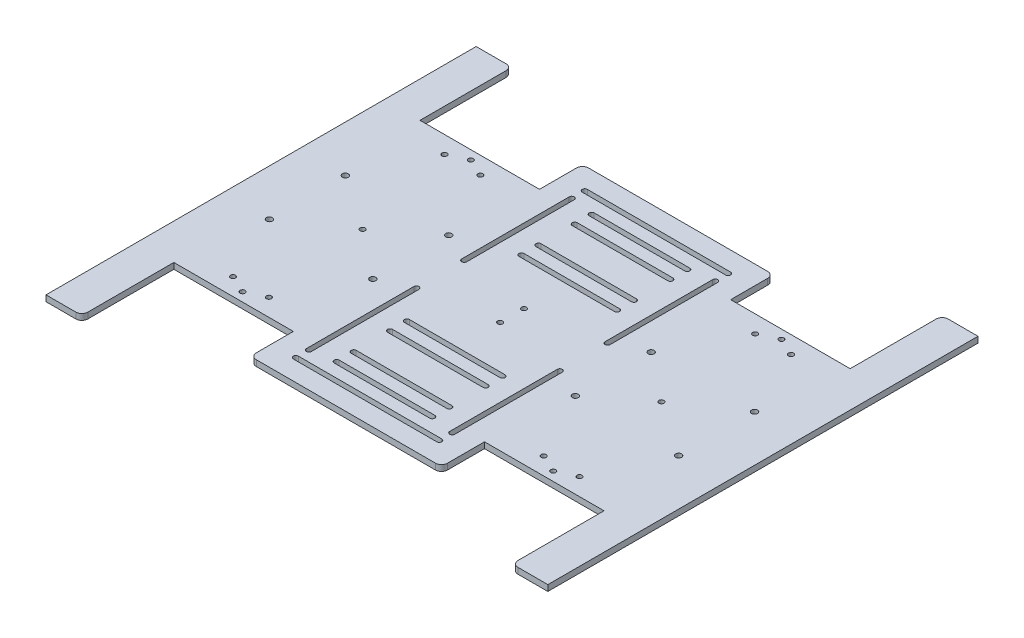
from build123d import *

# Parameters (mm, degrees)
EXTRUDE_1_DEPTH     = 5
SKETCH_2_R          = 2.1
CUT_EXTRUDE_1_DEPTH = 6
FILLET_1_R          = 5
SKETCH_3_R          = 2.5
CUT_EXTRUDE_2_DEPTH = 6
SKETCH_4_R          = 2.1
CUT_EXTRUDE_3_DEPTH = 6
SKETCH_5_W          = 160
SKETCH_5_H          = 66.889435481
CUT_EXTRUDE_4_DEPTH = 6
FILLET_2_R          = 5
CUT_EXTRUDE_5_DEPTH = 6


with BuildPart() as part:
    # 草图1 → 凸台-拉伸1 (new body)
    with BuildSketch(Plane(origin=(0, 0, 0), x_dir=(1, 0, 0), z_dir=(0, 1, 0))):
        Polygon((-180, 180), (-180, 103), (-80, 103), (-80, 180), (80, 180), (80, 103), (180, 103), (180, 180), (210, 180), (210, -180), (180, -180), (180, -103), (80, -103), (80, -180), (-80, -180), (-80, -103), (-180, -103), (-180, -180), (-210, -180), (-210, 180), align=None)
    extrude(amount=EXTRUDE_1_DEPTH)

    # 草图2 → 切除-拉伸1 (cut, through all)
    with BuildSketch(Plane(origin=(0, 5, 0), x_dir=(1, 0, 0), z_dir=(0, 1, 0))):
        with Locations((115, -88.5)):
            Circle(SKETCH_2_R)
        with Locations((145, -88.5)):
            Circle(SKETCH_2_R)
        with Locations((130, -95.5)):
            Circle(SKETCH_2_R)
        with Locations((130, 95.5)):
            Circle(SKETCH_2_R)
        with Locations((145, 88.5)):
            Circle(SKETCH_2_R)
        with Locations((115, 88.5)):
            Circle(SKETCH_2_R)
        with Locations((-115, 88.5)):
            Circle(SKETCH_2_R)
        with Locations((-145, 88.5)):
            Circle(SKETCH_2_R)
        with Locations((-130, 95.5)):
            Circle(SKETCH_2_R)
        with Locations((-130, -95.5)):
            Circle(SKETCH_2_R)
        with Locations((-145, -88.5)):
            Circle(SKETCH_2_R)
        with Locations((-115, -88.5)):
            Circle(SKETCH_2_R)
    extrude(amount=-CUT_EXTRUDE_1_DEPTH, mode=Mode.SUBTRACT)

    # 圆角1
    fillet_1_edges = [part.edges().sort_by_distance(p)[0] for p in [
        (180, 2.5, 180),
        (80, 2.5, 180),
        (-80, 2.5, 180),
        (-180, 2.5, 180),
        (-180, 2.5, -180),
        (-80, 2.5, -180),
        (80, 2.5, -180),
        (180, 2.5, -180),
    ]]
    fillet(fillet_1_edges, radius=FILLET_1_R)

    # 草图3 → 切除-拉伸2 (cut, through all)
    with BuildSketch(Plane.XZ):
        with Locations((84.75, 31.75)):
            Circle(SKETCH_3_R)
        with Locations((84.75, -31.75)):
            Circle(SKETCH_3_R)
        with Locations((171.25, 31.75)):
            Circle(SKETCH_3_R)
        with Locations((171.25, -31.75)):
            Circle(SKETCH_3_R)
        with Locations((-171.25, -31.75)):
            Circle(SKETCH_3_R)
        with Locations((-171.25, 31.75)):
            Circle(SKETCH_3_R)
        with Locations((-84.75, -31.75)):
            Circle(SKETCH_3_R)
        with Locations((-84.75, 31.75)):
            Circle(SKETCH_3_R)
    extrude(amount=-CUT_EXTRUDE_2_DEPTH, mode=Mode.SUBTRACT)

    # 草图4 → 切除-拉伸3 (cut, through all)
    with BuildSketch(Plane.XZ):
        with Locations((-125, 0)):
            Circle(SKETCH_4_R)
        with Locations((125, 0)):
            Circle(SKETCH_4_R)
        with Locations((0, 10)):
            Circle(SKETCH_4_R)
        with Locations((0, -10)):
            Circle(SKETCH_4_R)
    extrude(amount=-CUT_EXTRUDE_3_DEPTH, mode=Mode.SUBTRACT)

    # 草图5 → 切除-拉伸4 (cut, through all)
    with BuildSketch(Plane(origin=(0, 5, 0), x_dir=(1, 0, 0), z_dir=(0, 1, 0))):
        with Locations((0, -172.444717741)):
            Rectangle(SKETCH_5_W, SKETCH_5_H)
        Polygon((80, 139), (-80, 139), (-80, 214.558464343), (80, 221.06023599), align=None)
    extrude(amount=-CUT_EXTRUDE_4_DEPTH, mode=Mode.SUBTRACT)

    # 圆角2
    fillet_2_edges = [part.edges().sort_by_distance(p)[0] for p in [
        (-80, 2.5, 139),
        (80, 2.5, 139),
        (80, 2.5, -139),
        (-80, 2.5, -139),
    ]]
    fillet(fillet_2_edges, radius=FILLET_2_R)

    # 草图6 → 切除-拉伸5 (cut, through all)
    with BuildSketch(Plane(origin=(0, 5, 0), x_dir=(1, 0, 0), z_dir=(0, 1, 0))):
        with BuildLine():
            Line((-60, 123), (60, 123))
            ThreePointArc((60, 123), (62.1, 120.9), (60, 118.8))
            Line((60, 118.8), (-60, 118.8))
            ThreePointArc((-60, 118.8), (-62.1, 120.9), (-60, 123))
        make_face()
        with BuildLine():
            Line((-40, 108.8), (40, 108.8))
            ThreePointArc((40, 108.8), (42.1, 106.7), (40, 104.6))
            Line((40, 104.6), (-40, 104.6))
            ThreePointArc((-40, 104.6), (-42.1, 106.7), (-40, 108.8))
        make_face()
        with BuildLine():
            Line((-62.1, 110), (-62.1, 20))
            ThreePointArc((-62.1, 20), (-60, 17.9), (-57.9, 20))
            Line((-57.9, 20), (-57.9, 110))
            ThreePointArc((-57.9, 110), (-60, 112.1), (-62.1, 110))
        make_face()
        with BuildLine():
            Line((-40, 94.6), (40, 94.6))
            ThreePointArc((40, 94.6), (42.1, 92.5), (40, 90.4))
            Line((40, 90.4), (-40, 90.4))
            ThreePointArc((-40, 90.4), (-42.1, 92.5), (-40, 94.6))
        make_face()
        with BuildLine():
            Line((62.1, 110), (62.1, 20))
            ThreePointArc((62.1, 20), (60, 17.9), (57.9, 20))
            Line((57.9, 20), (57.9, 110))
            ThreePointArc((57.9, 110), (60, 112.1), (62.1, 110))
        make_face()
        with BuildLine():
            Line((-40, 64.2), (40, 64.2))
            ThreePointArc((40, 64.2), (42.1, 62.1), (40, 60))
            Line((40, 60), (-40, 60))
            ThreePointArc((-40, 60), (-42.1, 62.1), (-40, 64.2))
        make_face()
        with BuildLine():
            Line((-40, 50), (40, 50))
            ThreePointArc((40, 50), (42.1, 47.9), (40, 45.8))
            Line((40, 45.8), (-40, 45.8))
            ThreePointArc((-40, 45.8), (-42.1, 47.9), (-40, 50))
        make_face()
        with BuildLine():
            Line((40, -60), (-40, -60))
            ThreePointArc((-40, -60), (-42.1, -62.1), (-40, -64.2))
            Line((-40, -64.2), (40, -64.2))
            ThreePointArc((40, -64.2), (42.1, -62.1), (40, -60))
        make_face()
        with BuildLine():
            Line((40, -45.8), (-40, -45.8))
            ThreePointArc((-40, -45.8), (-42.1, -47.9), (-40, -50))
            Line((-40, -50), (40, -50))
            ThreePointArc((40, -50), (42.1, -47.9), (40, -45.8))
        make_face()
        with BuildLine():
            Line((-57.9, -110), (-57.9, -20))
            ThreePointArc((-57.9, -20), (-60, -17.9), (-62.1, -20))
            Line((-62.1, -20), (-62.1, -110))
            ThreePointArc((-62.1, -110), (-60, -112.1), (-57.9, -110))
        make_face()
        with BuildLine():
            Line((57.9, -20), (57.9, -110))
            ThreePointArc((57.9, -110), (60, -112.1), (62.1, -110))
            Line((62.1, -110), (62.1, -20))
            ThreePointArc((62.1, -20), (60, -17.9), (57.9, -20))
        make_face()
        with BuildLine():
            Line((40, -90.4), (-40, -90.4))
            ThreePointArc((-40, -90.4), (-42.1, -92.5), (-40, -94.6))
            Line((-40, -94.6), (40, -94.6))
            ThreePointArc((40, -94.6), (42.1, -92.5), (40, -90.4))
        make_face()
        with BuildLine():
            Line((40, -104.6), (-40, -104.6))
            ThreePointArc((-40, -104.6), (-42.1, -106.7), (-40, -108.8))
            Line((-40, -108.8), (40, -108.8))
            ThreePointArc((40, -108.8), (42.1, -106.7), (40, -104.6))
        make_face()
        with BuildLine():
            Line((60, -118.8), (-60, -118.8))
            ThreePointArc((-60, -118.8), (-62.1, -120.9), (-60, -123))
            Line((-60, -123), (60, -123))
            ThreePointArc((60, -123), (62.1, -120.9), (60, -118.8))
        make_face()
    extrude(amount=-CUT_EXTRUDE_5_DEPTH, mode=Mode.SUBTRACT)


solid = part.part
